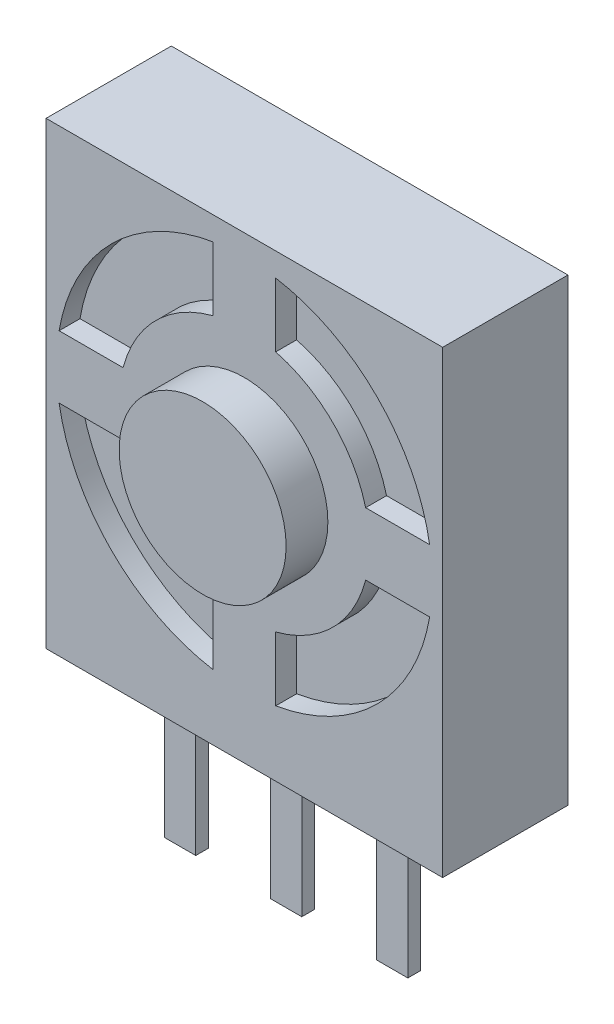
from build123d import *

# Parameters (mm, degrees)
ESQUISSE1_W                = 9.5
ESQUISSE1_H                = 11
BOSS_EXTRU_1_DEPTH         = 3
ESQUISSE2_R                = 2
BOSS_EXTRU_2_DEPTH         = 1
ENL_V_MAT_EXTRU_1_DEPTH    = 0.5
BOSS_EXTRU_3_START         = 2.54
ESQUISSE5_W                = 0.3
ESQUISSE5_H                = 3.5
BOSS_EXTRU_3_DEPTH         = 0.375
R_P_TITION_LIN_AIRE1_COUNT = 3
R_P_TITION_LIN_AIRE1_PITCH = 2.54


with BuildPart() as part:
    # Esquisse1 → Boss.-Extru.1 (new body)
    with BuildSketch(Plane.XY):
        Rectangle(ESQUISSE1_W, ESQUISSE1_H)
    extrude(amount=BOSS_EXTRU_1_DEPTH)

    # Esquisse2 → Boss.-Extru.2 (add)
    with BuildSketch(Plane.XY.offset(3)):
        with Locations((0, 0.5)):
            Circle(ESQUISSE2_R)
    extrude(amount=BOSS_EXTRU_2_DEPTH)

    # Esquisse3 → Enlèv. mat.-Extru.1 (cut)
    with BuildSketch(Plane.XY.offset(3)):
        with BuildLine():
            Line((-0.75, 3.40473751), (-0.75, 4.937059837))
            ThreePointArc((-0.75, 4.937059837), (-3.181980515, 3.681980515), (-4.437059837, 1.25))
            Line((-4.437059837, 1.25), (-2.90473751, 1.25))
            ThreePointArc((-2.90473751, 1.25), (-2.121320344, 2.621320344), (-0.75, 3.40473751))
        make_face()
        with BuildLine():
            Line((2.90473751, 1.25), (4.437059837, 1.25))
            ThreePointArc((4.437059837, 1.25), (3.181980515, 3.681980515), (0.75, 4.937059837))
            Line((0.75, 4.937059837), (0.75, 3.40473751))
            ThreePointArc((0.75, 3.40473751), (2.121320344, 2.621320344), (2.90473751, 1.25))
        make_face()
        with BuildLine():
            ThreePointArc((0.75, -3.937059837), (3.181980515, -2.681980515), (4.437059837, -0.25))
            Line((4.437059837, -0.25), (2.90473751, -0.25))
            ThreePointArc((2.90473751, -0.25), (2.121320344, -1.621320344), (0.75, -2.40473751))
            Line((0.75, -2.40473751), (0.75, -3.937059837))
        make_face()
        with BuildLine():
            ThreePointArc((-4.437059837, -0.25), (-3.181980515, -2.681980515), (-0.75, -3.937059837))
            Line((-0.75, -3.937059837), (-0.75, -2.40473751))
            ThreePointArc((-0.75, -2.40473751), (-2.121320344, -1.621320344), (-2.90473751, -0.25))
            Line((-2.90473751, -0.25), (-4.437059837, -0.25))
        make_face()
    extrude(amount=-ENL_V_MAT_EXTRU_1_DEPTH, mode=Mode.SUBTRACT)


with BuildPart() as body_2:
    # Esquisse5 → Boss.-Extru.3 (new body, symmetric)
    with BuildSketch(Plane(origin=(0, 0, 0), x_dir=(0, 0, -1), z_dir=(1, 0, 0)).offset(BOSS_EXTRU_3_START)):
        with Locations((-1.85, -7.25)):
            Rectangle(ESQUISSE5_W, ESQUISSE5_H)
    extrude(amount=BOSS_EXTRU_3_DEPTH, both=True)


with BuildPart() as r_p_tition_lin_aire1_1:
    # Répétition linéaire1: pattern copy
    add(body_2.part.moved(Location(Vector(-1, 0, 0) * (1 * R_P_TITION_LIN_AIRE1_PITCH))))


with BuildPart() as r_p_tition_lin_aire1_2:
    # Répétition linéaire1: pattern copy
    add(body_2.part.moved(Location(Vector(-1, 0, 0) * (2 * R_P_TITION_LIN_AIRE1_PITCH))))


solid = Compound([part.part, body_2.part, r_p_tition_lin_aire1_1.part, r_p_tition_lin_aire1_2.part])
